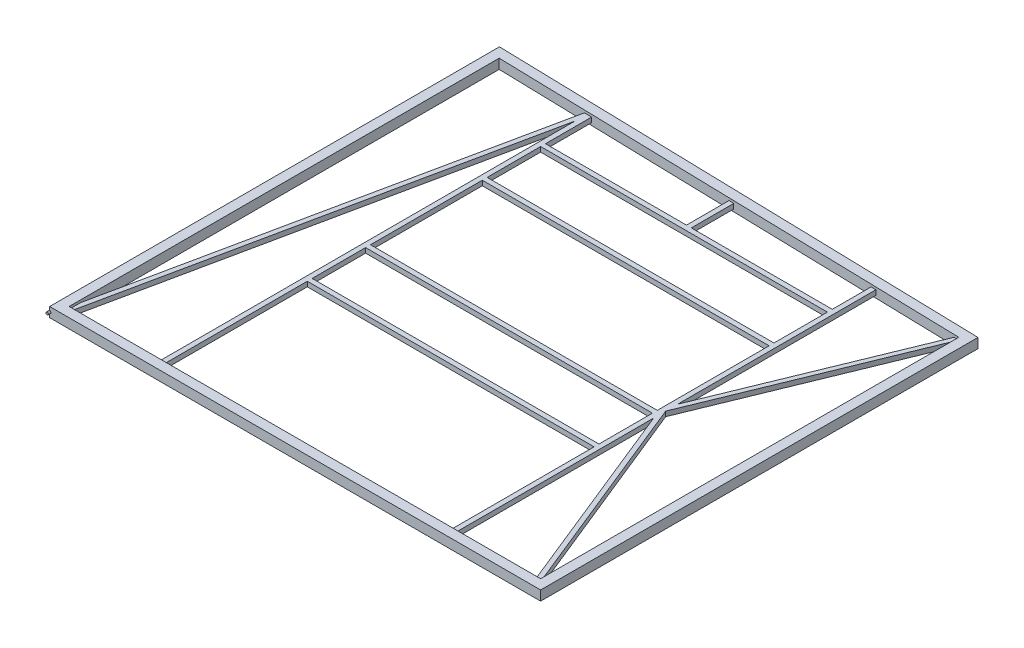
from build123d import *

# Parameters (mm, degrees)
SKETCH2_W           = 50.8
SKETCH2_H           = 50.8
SKETCH2_W_2         = 44.45
SKETCH2_H_2         = 44.45
BOSS_EXTRUDE2_REACH = 2301.35
SKETCH4_W           = 25.4
SKETCH4_H           = 25.4
SKETCH4_W_2         = 19.05
SKETCH4_H_2         = 19.05
SKETCH5_W           = 25.4
SKETCH5_H           = 25.4
SKETCH5_W_2         = 19.05
SKETCH5_H_2         = 19.05
BOSS_EXTRUDE3_DEPTH = 1498.6
SKETCH6_W           = 25.4
SKETCH6_H           = 25.4
BOSS_EXTRUDE4_REACH = 307.45
SKETCH8_W           = 25.4
SKETCH8_H           = 25.4
SKETCH8_W_2         = 19.05
SKETCH8_H_2         = 19.05
SKETCH9_W           = 25.4
SKETCH9_H           = 25.4
SKETCH9_W_2         = 19.05
SKETCH9_H_2         = 19.05
SKETCH11_R          = 6.35
BOSS_EXTRUDE5_DEPTH = 12.7
SKETCH13_R          = 6.35
BOSS_EXTRUDE6_DEPTH = 15.875


with BuildPart() as part:
    # Sweep1: sweep along a path in Sketch1
    with BuildLine(Plane(origin=(0, 0, 0), x_dir=(1, 0, 0), z_dir=(0, 1, 0))) as sweep1_path:
        Line((0, 2298.7), (0, 0))
        Line((0, 0), (2514.6, 0))
        Line((2514.6, 0), (2514.6, 2235.2))
        Line((2514.6, 2235.2), (0, 2298.7))
    # Sketch2 → Sweep1 (sweep)
    with BuildSketch(Plane.XY.offset(-1016)):
        Rectangle(SKETCH2_W, SKETCH2_H)
        Rectangle(SKETCH2_W_2, SKETCH2_H_2, mode=Mode.SUBTRACT)
    sweep(path=sweep1_path.line, transition=Transition.RIGHT)

    # Boss-Extrude2: up to this face of the body (flat: up to its plane)
    boss_extrude2_end = Plane(part.part.faces().sort_by_distance((1257.3, 0, -2241.541902627))[0])
    # Sketch4 → Boss-Extrude2 (add, up to the picked face)
    with BuildSketch(Plane(origin=(0, 0, -25.4), x_dir=(-1, 0, 0), z_dir=(0, 0, -1)), mode=Mode.PRIVATE) as boss_extrude2_sk1:
        with Locations((-2032, 0)):
            Rectangle(SKETCH4_W, SKETCH4_H)
        with Locations((-2032, 0)):
            Rectangle(SKETCH4_W_2, SKETCH4_H_2, mode=Mode.SUBTRACT)
    boss_extrude2_tool1 = split(extrude(boss_extrude2_sk1.sketch, amount=BOSS_EXTRUDE2_REACH, mode=Mode.PRIVATE), bisect_by=boss_extrude2_end, keep=Keep.BOTH, mode=Mode.PRIVATE)
    add(boss_extrude2_tool1.solids().sort_by_distance((2032, -12.34079, -25.4))[0])
    # Sketch4 → Boss-Extrude2 (add, up to the picked face)
    with BuildSketch(Plane(origin=(0, 0, -25.4), x_dir=(-1, 0, 0), z_dir=(0, 0, -1)), mode=Mode.PRIVATE) as boss_extrude2_sk2:
        with Locations((-508, 0)):
            Rectangle(SKETCH4_W, SKETCH4_H)
        with Locations((-508, 0)):
            Rectangle(SKETCH4_W_2, SKETCH4_H_2, mode=Mode.SUBTRACT)
    boss_extrude2_tool2 = split(extrude(boss_extrude2_sk2.sketch, amount=BOSS_EXTRUDE2_REACH, mode=Mode.PRIVATE), bisect_by=boss_extrude2_end, keep=Keep.BOTH, mode=Mode.PRIVATE)
    add(boss_extrude2_tool2.solids().sort_by_distance((495.65921, 0, -25.4))[0])

    # Sketch5 → Boss-Extrude3 (add)
    with BuildSketch(Plane(origin=(520.7, 0, 0), x_dir=(0, 0, -1), z_dir=(1, 0, 0))):
        with Locations((787.4, 0)):
            Rectangle(SKETCH5_W, SKETCH5_H)
        with Locations((787.4, 0)):
            Rectangle(SKETCH5_W_2, SKETCH5_H_2, mode=Mode.SUBTRACT)
        with Locations((1092.2, 0)):
            Rectangle(SKETCH5_W, SKETCH5_H)
        with Locations((1092.2, 0)):
            Rectangle(SKETCH5_W_2, SKETCH5_H_2, mode=Mode.SUBTRACT)
        with Locations((1701.8, 0)):
            Rectangle(SKETCH5_W, SKETCH5_H)
        with Locations((1701.8, 0)):
            Rectangle(SKETCH5_W_2, SKETCH5_H_2, mode=Mode.SUBTRACT)
        with Locations((2006.6, 0)):
            Rectangle(SKETCH5_W, SKETCH5_H)
        with Locations((2006.6, 0)):
            Rectangle(SKETCH5_W_2, SKETCH5_H_2, mode=Mode.SUBTRACT)
    extrude(amount=BOSS_EXTRUDE3_DEPTH)

    # Sweep2: sweep along a path in Sketch7
    with BuildLine(Plane(origin=(0, 25.4, 0), x_dir=(1, 0, 0), z_dir=(0, 1, 0))) as sweep2_path:
        Line((25.4, 25.4), (495.3, 2260.78432687))
    # Sketch6 → Sweep2 (sweep)
    with BuildSketch(Plane(origin=(0, 0, -25.4), x_dir=(-1, 0, 0), z_dir=(0, 0, -1))):
        with Locations((-25.4, 0)):
            Rectangle(SKETCH6_W, SKETCH6_H)
    sweep(path=sweep2_path.line)

    # Boss-Extrude4: up to this face of the body (flat: up to its plane)
    boss_extrude4_end = Plane(part.part.faces().sort_by_distance((1257.167708333, 0, -2241.545243326))[0])
    # Sketch8 → Boss-Extrude4 (add, up to the picked face)
    with BuildSketch(Plane(origin=(0, 0, -2019.3), x_dir=(-1, 0, 0), z_dir=(0, 0, -1)), mode=Mode.PRIVATE) as boss_extrude4_sk1:
        with Locations((-1270, 0)):
            Rectangle(SKETCH8_W, SKETCH8_H)
        with Locations((-1270, 0)):
            Rectangle(SKETCH8_W_2, SKETCH8_H_2, mode=Mode.SUBTRACT)
    boss_extrude4_tool1 = split(extrude(boss_extrude4_sk1.sketch, amount=BOSS_EXTRUDE4_REACH, mode=Mode.PRIVATE), bisect_by=boss_extrude4_end, keep=Keep.BOTH, mode=Mode.PRIVATE)
    add(boss_extrude4_tool1.solids().sort_by_distance((1270, -12.34079, -2019.3))[0])

    # Sweep4: sweep along a path in Sketch10
    with BuildLine(Plane(origin=(0, 25.4, 0), x_dir=(1, 0, 0), z_dir=(0, 1, 0))) as sweep4_path:
        Line((2489.2, 25.4), (2044.7, 1123.529032122))
        Line((2044.7, 1123.529032122), (2489.2, 2210.433316769))
    # Sketch9 → Sweep4 (sweep)
    with BuildSketch(Plane(origin=(0, 0, -25.4), x_dir=(-1, 0, 0), z_dir=(0, 0, -1))):
        with Locations((-2476.5, 0)):
            Rectangle(SKETCH9_W, SKETCH9_H)
        with Locations((-2476.5, 0)):
            Rectangle(SKETCH9_W_2, SKETCH9_H_2, mode=Mode.SUBTRACT)
    sweep(path=sweep4_path.line, transition=Transition.RIGHT)

    # Sketch11 → Boss-Extrude5 (add, symmetric)
    with BuildSketch(Plane.XY.offset(25.4)):
        with Locations((-25.4, 0)):
            Circle(SKETCH11_R)
    extrude(amount=BOSS_EXTRUDE5_DEPTH, both=True)

    # Sketch13 → Boss-Extrude6 (add, symmetric)
    with BuildSketch(Plane.XY.offset(-2324.749511514)):
        with Locations((-25.4, 0)):
            Circle(SKETCH13_R)
    extrude(amount=BOSS_EXTRUDE6_DEPTH, both=True)


solid = part.part
